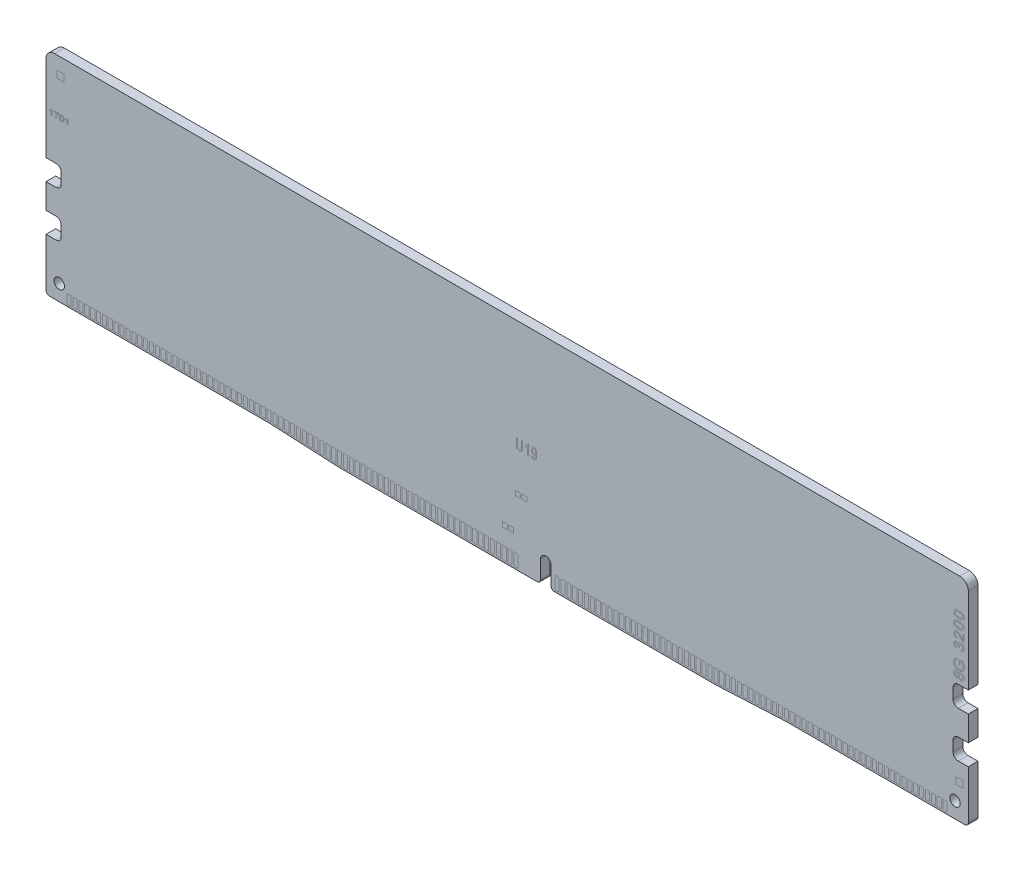
from build123d import *

# Parameters (mm, degrees)
SKETCH1_W           = 133.35
SKETCH1_H           = 31.25
BOSS_EXTRUDE1_DEPTH = 0.7
SKETCH2_R           = 0.75
CUT_EXTRUDE1_DEPTH  = 1.4
FILLET1_R           = 1.25
FILLET2_R           = 0.5


with BuildPart() as part:
    # Sketch1 → Boss-Extrude1 (new body, symmetric)
    with BuildSketch(Plane.XY):
        Rectangle(SKETCH1_W, SKETCH1_H)
    extrude(amount=BOSS_EXTRUDE1_DEPTH, both=True)

    # Sketch2 → Cut-Extrude1 (cut)
    with BuildSketch(Plane.XY.offset(0.7)):
        Polygon((66.675, -15.625), (66.675, -15.125), (40.375, -15.125), (30.175, -15.625), align=None)
        Polygon((-34.425, -15.125), (-66.675, -15.125), (-66.675, -15.625), (-24.225, -15.625), align=None)
        with BuildLine():
            Line((-65.225, 1.975), (-66.675, 1.975))
            Line((-66.675, 1.975), (-66.675, -1.025))
            Line((-66.675, -1.025), (-65.225, -1.025))
            ThreePointArc((-65.225, -1.025), (-64.694669914, -0.805330086), (-64.475, -0.275))
            Line((-64.475, -0.275), (-64.475, 1.225))
            ThreePointArc((-64.475, 1.225), (-64.694669914, 1.755330086), (-65.225, 1.975))
        make_face()
        with BuildLine():
            Line((-65.225, -4.625), (-66.675, -4.625))
            Line((-66.675, -4.625), (-66.675, -7.625))
            Line((-66.675, -7.625), (-65.225, -7.625))
            ThreePointArc((-65.225, -7.625), (-64.694669914, -7.405330086), (-64.475, -6.875))
            Line((-64.475, -6.875), (-64.475, -5.375))
            ThreePointArc((-64.475, -5.375), (-64.694669914, -4.844669914), (-65.225, -4.625))
        make_face()
        with BuildLine():
            Line((66.675, -1.025), (66.675, 1.975))
            Line((66.675, 1.975), (65.225, 1.975))
            ThreePointArc((65.225, 1.975), (64.694669914, 1.755330086), (64.475, 1.225))
            Line((64.475, 1.225), (64.475, -0.275))
            ThreePointArc((64.475, -0.275), (64.694669914, -0.805330086), (65.225, -1.025))
            Line((65.225, -1.025), (66.675, -1.025))
        make_face()
        with BuildLine():
            Line((66.675, -7.625), (66.675, -4.625))
            Line((66.675, -4.625), (65.225, -4.625))
            ThreePointArc((65.225, -4.625), (64.694669914, -4.844669914), (64.475, -5.375))
            Line((64.475, -5.375), (64.475, -6.875))
            ThreePointArc((64.475, -6.875), (64.694669914, -7.405330086), (65.225, -7.625))
            Line((65.225, -7.625), (66.675, -7.625))
        make_face()
        with BuildLine():
            Line((4.825, -15.625), (6.325, -15.625))
            Line((6.325, -15.625), (6.325, -12.525))
            ThreePointArc((6.325, -12.525), (5.575, -11.775), (4.825, -12.525))
            Line((4.825, -12.525), (4.825, -15.625))
        make_face()
        with Locations((-64.75, -12.825)):
            Circle(SKETCH2_R)
        with Locations((64.75, -12.825)):
            Circle(SKETCH2_R)
    extrude(amount=-CUT_EXTRUDE1_DEPTH, mode=Mode.SUBTRACT)

    # Fillet1
    fillet1_edges = [part.edges().sort_by_distance(p)[0] for p in [
        (-66.675, 15.625, 0),
        (66.675, 15.625, 0),
    ]]
    fillet(fillet1_edges, radius=FILLET1_R)

    # Fillet2
    fillet2_edges = [part.edges().sort_by_distance(p)[0] for p in [
        (6.325, -15.625, 0),
        (4.825, -15.625, 0),
        (40.375, -15.125, 0),
        (66.675, -15.125, 0),
        (30.175, -15.625, 0),
        (-34.425, -15.125, 0),
        (-24.225, -15.625, 0),
        (-66.675, -15.125, 0),
    ]]
    fillet(fillet2_edges, radius=FILLET2_R)


solid = part.part
